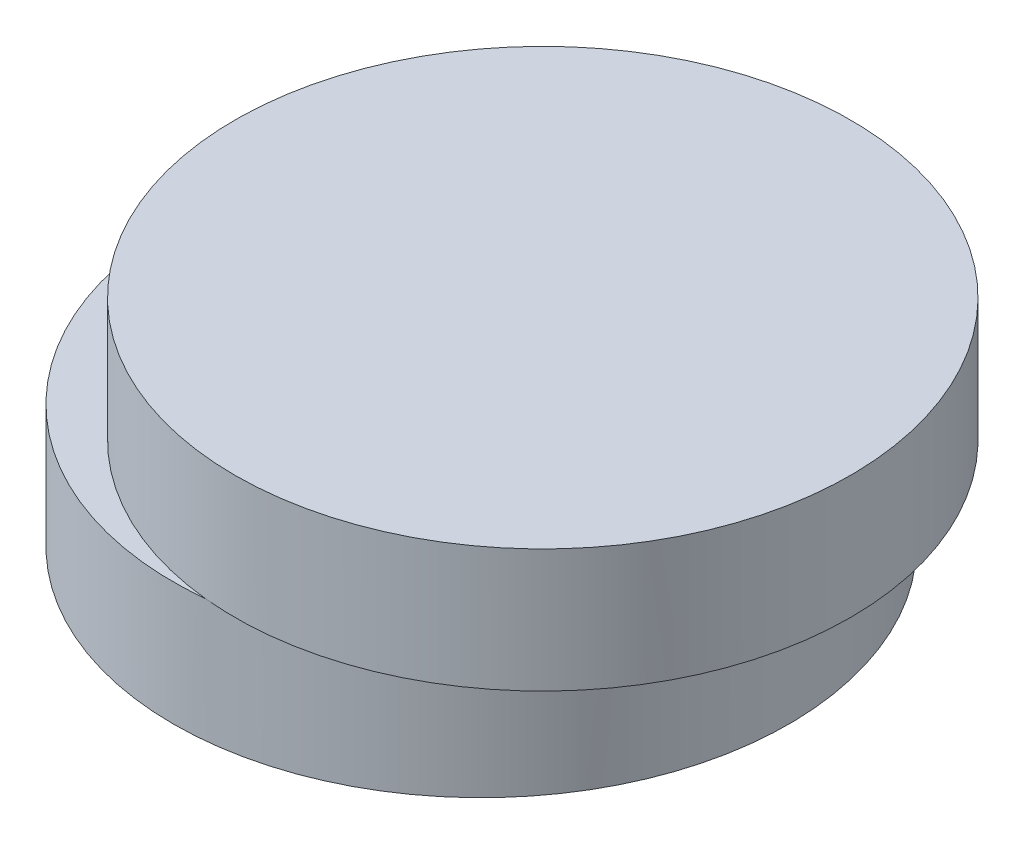
from build123d import *

# Parameters (mm, degrees)
SKETCH1_R           = 5
BOSS_EXTRUDE1_DEPTH = 2
SKETCH2_R           = 5
BOSS_EXTRUDE2_DEPTH = 2


with BuildPart() as part:
    # Sketch1 → Boss-Extrude1 (new body)
    with BuildSketch(Plane(origin=(0, 0, 0), x_dir=(1, 0, 0), z_dir=(0, 1, 0))):
        Circle(SKETCH1_R)
    extrude(amount=BOSS_EXTRUDE1_DEPTH)

    # Sketch2 → Boss-Extrude2 (add)
    with BuildSketch(Plane(origin=(0, 2, 0), x_dir=(1, 0, 0), z_dir=(0, 1, 0))):
        with Locations((1, 0)):
            Circle(SKETCH2_R)
    extrude(amount=BOSS_EXTRUDE2_DEPTH)


solid = part.part
